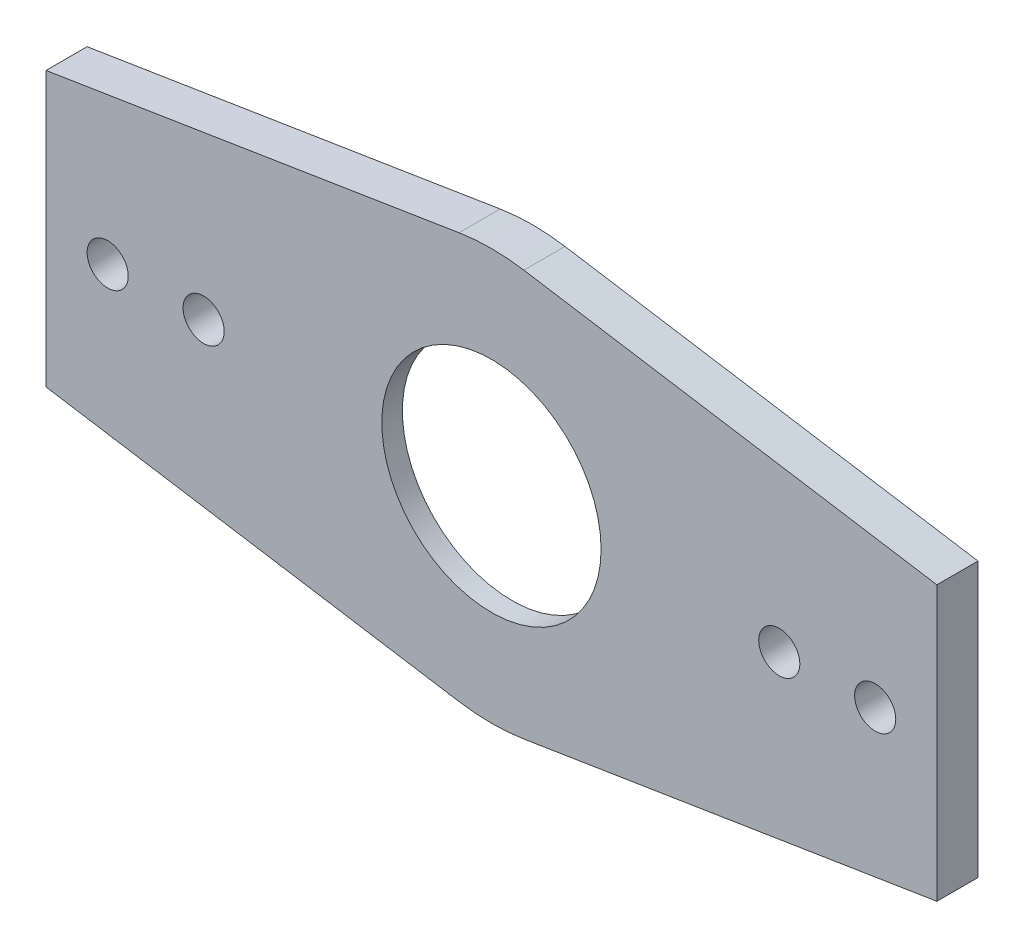
from build123d import *

# Parameters (mm, degrees)
SKETCH1_R           = 3
SKETCH1_R_2         = 16
BOSS_EXTRUDE1_DEPTH = 3
SKETCH3_R           = 30
SKETCH3_R_2         = 21
BOSS_EXTRUDE3_DEPTH = 3.5
SKETCH4_R           = 3
BOSS_EXTRUDE4_DEPTH = 3.5
SKETCH5_R           = 3
SKETCH5_R_2         = 21
CUT_EXTRUDE1_DEPTH  = 0.5


with BuildPart() as part:
    # Sketch1 → Boss-Extrude1 (new body)
    with BuildSketch(Plane.XY):
        with BuildLine():
            Line((-65, 20), (-65, -20))
            Line((-65, -20), (-4.730882844, -29.624630757))
            ThreePointArc((-4.730882844, -29.624630757), (0, -30), (4.730882844, -29.624630757))
            Line((4.730882844, -29.624630757), (65, -20))
            Line((65, -20), (65, 20))
            Line((65, 20), (4.730882844, 29.624630757))
            ThreePointArc((4.730882844, 29.624630757), (0, 30), (-4.730882844, 29.624630757))
            Line((-4.730882844, 29.624630757), (-65, 20))
        make_face()
        with Locations((56, 0)):
            Circle(SKETCH1_R, mode=Mode.SUBTRACT)
        with Locations((42, 0)):
            Circle(SKETCH1_R, mode=Mode.SUBTRACT)
        with Locations((-56, 0)):
            Circle(SKETCH1_R, mode=Mode.SUBTRACT)
        with Locations((-42, 0)):
            Circle(SKETCH1_R, mode=Mode.SUBTRACT)
        Circle(SKETCH1_R_2, mode=Mode.SUBTRACT)
    extrude(amount=BOSS_EXTRUDE1_DEPTH)

    # Sketch3 → Boss-Extrude3 (add)
    with BuildSketch(Plane(origin=(0, 0, 0), x_dir=(-1, 0, 0), z_dir=(0, 0, -1))):
        Circle(SKETCH3_R)
        Circle(SKETCH3_R_2, mode=Mode.SUBTRACT)
    extrude(amount=BOSS_EXTRUDE3_DEPTH)

    # Sketch4 → Boss-Extrude4 (add)
    with BuildSketch(Plane(origin=(0, 0, 0), x_dir=(-1, 0, 0), z_dir=(0, 0, -1))):
        with BuildLine():
            Line((4.730882844, -29.624630757), (65, -20))
            Line((65, -20), (65, 20))
            Line((65, 20), (4.730882844, 29.624630757))
            ThreePointArc((4.730882844, 29.624630757), (30, 0), (4.730882844, -29.624630757))
        make_face()
        with Locations((56, 0)):
            Circle(SKETCH4_R, mode=Mode.SUBTRACT)
        with Locations((42, 0)):
            Circle(SKETCH4_R, mode=Mode.SUBTRACT)
        with BuildLine():
            Line((-4.730882844, 29.624630757), (-65, 20))
            Line((-65, 20), (-65, -20))
            Line((-65, -20), (-4.730882844, -29.624630757))
            ThreePointArc((-4.730882844, -29.624630757), (-30, 0), (-4.730882844, 29.624630757))
        make_face()
        with Locations((-42, 0)):
            Circle(SKETCH4_R, mode=Mode.SUBTRACT)
        with Locations((-56, 0)):
            Circle(SKETCH4_R, mode=Mode.SUBTRACT)
    extrude(amount=BOSS_EXTRUDE4_DEPTH)

    # Sketch5 → Cut-Extrude1 (cut)
    with BuildSketch(Plane(origin=(0, 0, -3.5), x_dir=(-1, 0, 0), z_dir=(0, 0, -1))):
        with BuildLine():
            Line((-4.730882844, 29.624630757), (-65, 20))
            Line((-65, 20), (-65, -20))
            Line((-65, -20), (-4.730882844, -29.624630757))
            ThreePointArc((-4.730882844, -29.624630757), (0, -30), (4.730882844, -29.624630757))
            Line((4.730882844, -29.624630757), (65, -20))
            Line((65, -20), (65, 20))
            Line((65, 20), (4.730882844, 29.624630757))
            ThreePointArc((4.730882844, 29.624630757), (0, 30), (-4.730882844, 29.624630757))
        make_face()
        with Locations((56, 0)):
            Circle(SKETCH5_R, mode=Mode.SUBTRACT)
        with Locations((42, 0)):
            Circle(SKETCH5_R, mode=Mode.SUBTRACT)
        Circle(SKETCH5_R_2, mode=Mode.SUBTRACT)
        with Locations((-42, 0)):
            Circle(SKETCH5_R, mode=Mode.SUBTRACT)
        with Locations((-56, 0)):
            Circle(SKETCH5_R, mode=Mode.SUBTRACT)
    extrude(amount=-CUT_EXTRUDE1_DEPTH, mode=Mode.SUBTRACT)


solid = part.part
